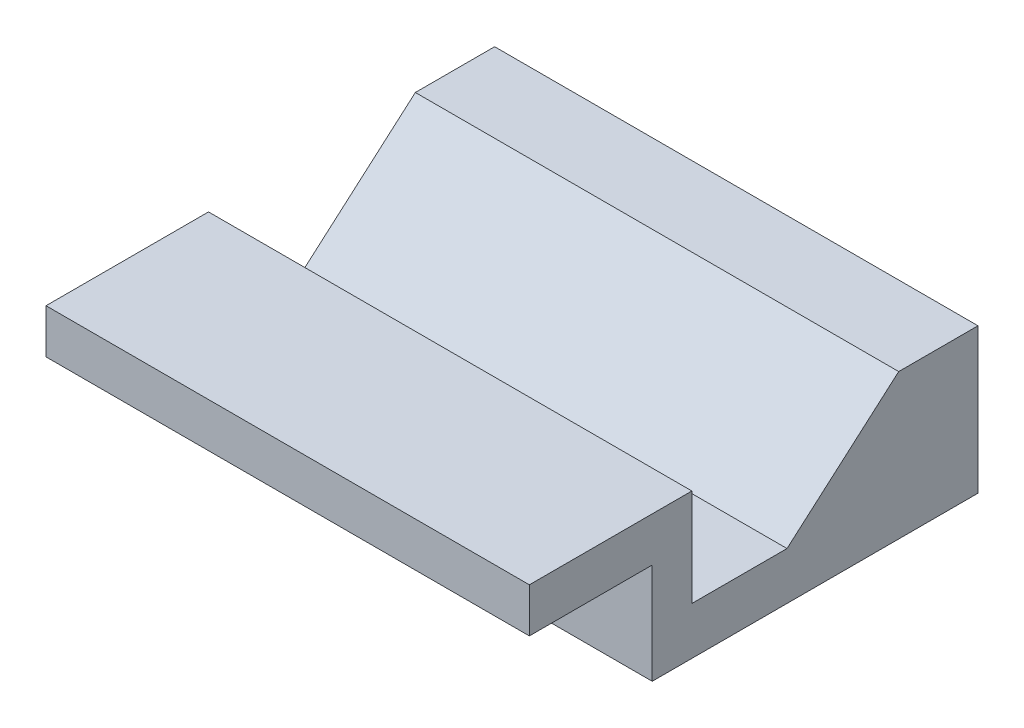
from build123d import *

# Parameters (mm, degrees)
BOSS_EXTRUDE1_DEPTH = 30.48


with BuildPart() as part:
    # Sketch1 → Boss-Extrude1 (new body)
    with BuildSketch(Plane(origin=(0, 0, 0), x_dir=(0, 0, -1), z_dir=(1, 0, 0))):
        Polygon((10.247, -6.144), (10.247, 0), (0, 0), (0, -2.794), (7.747, -2.794), (7.747, -9.144), (28.29, -9.144), (28.29, 0), (23.29, 0), (16.247, -6.144), align=None)
    extrude(amount=BOSS_EXTRUDE1_DEPTH)


solid = part.part
